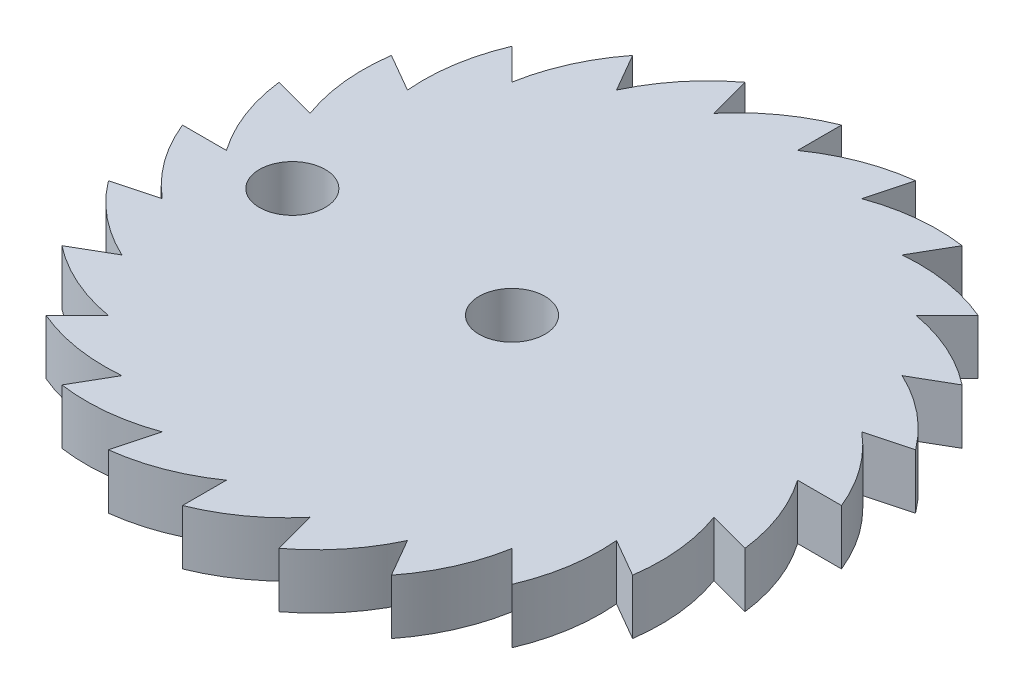
from build123d import *

# Parameters (mm, degrees)
SKETCH_1_R      = 1.5
EXTRUDE_1_DEPTH = 2.5


with BuildPart() as part:
    # 草图1 → 凸台-拉伸1 (new body)
    with BuildSketch(Plane(origin=(0, 0, 0), x_dir=(1, 0, 0), z_dir=(0, 1, 0))):
        with BuildLine():
            Line((3.882285677, 14.488887394), (3.364647586, 12.557035742))
            ThreePointArc((3.364647586, 12.557035742), (5.405611466, 13.028620317), (7.5, 12.990381057))
            Line((7.5, 12.990381057), (6.5, 11.258330249))
            ThreePointArc((6.5, 11.258330249), (8.593474792, 11.185605648), (10.606601718, 10.606601718))
            Line((10.606601718, 10.606601718), (9.192388155, 9.192388155))
            ThreePointArc((9.192388155, 9.192388155), (11.195707011, 8.580310438), (12.990381057, 7.5))
            Line((12.990381057, 7.5), (11.258330249, 6.5))
            ThreePointArc((11.258330249, 6.5), (13.0349703, 5.390281252), (14.488887394, 3.882285677))
            Line((14.488887394, 3.882285677), (12.557035742, 3.364647586))
            ThreePointArc((12.557035742, 3.364647586), (13.985921904, 1.832913306), (15, 0))
            Line((15, 0), (13, 0))
            ThreePointArc((13, 0), (13.983756043, -1.849364653), (14.488887394, -3.882285677))
            Line((14.488887394, -3.882285677), (12.557035742, -3.364647586))
            ThreePointArc((12.557035742, -3.364647586), (13.028620317, -5.405611466), (12.990381057, -7.5))
            Line((12.990381057, -7.5), (11.258330249, -6.5))
            ThreePointArc((11.258330249, -6.5), (11.185605648, -8.593474792), (10.606601718, -10.606601718))
            Line((10.606601718, -10.606601718), (9.192388155, -9.192388155))
            ThreePointArc((9.192388155, -9.192388155), (8.580310438, -11.195707011), (7.5, -12.990381057))
            Line((7.5, -12.990381057), (6.5, -11.258330249))
            ThreePointArc((6.5, -11.258330249), (5.390281252, -13.0349703), (3.882285677, -14.488887394))
            Line((3.882285677, -14.488887394), (3.364647586, -12.557035742))
            ThreePointArc((3.364647586, -12.557035742), (1.832913306, -13.985921904), (0, -15))
            Line((0, -15), (0, -13))
            ThreePointArc((0, -13), (-1.849364653, -13.983756043), (-3.882285677, -14.488887394))
            Line((-3.882285677, -14.488887394), (-3.364647586, -12.557035742))
            ThreePointArc((-3.364647586, -12.557035742), (-5.405611466, -13.028620317), (-7.5, -12.990381057))
            Line((-7.5, -12.990381057), (-6.5, -11.258330249))
            ThreePointArc((-6.5, -11.258330249), (-8.593474792, -11.185605648), (-10.606601718, -10.606601718))
            Line((-10.606601718, -10.606601718), (-9.192388155, -9.192388155))
            ThreePointArc((-9.192388155, -9.192388155), (-11.195707011, -8.580310438), (-12.990381057, -7.5))
            Line((-12.990381057, -7.5), (-11.258330249, -6.5))
            ThreePointArc((-11.258330249, -6.5), (-13.0349703, -5.390281252), (-14.488887394, -3.882285677))
            Line((-14.488887394, -3.882285677), (-12.557035742, -3.364647586))
            ThreePointArc((-12.557035742, -3.364647586), (-13.985921904, -1.832913306), (-15, 0))
            Line((-15, 0), (-13, 0))
            ThreePointArc((-13, 0), (-13.983756043, 1.849364653), (-14.488887394, 3.882285677))
            Line((-14.488887394, 3.882285677), (-12.557035742, 3.364647586))
            ThreePointArc((-12.557035742, 3.364647586), (-13.028620317, 5.405611466), (-12.990381057, 7.5))
            Line((-12.990381057, 7.5), (-11.258330249, 6.5))
            ThreePointArc((-11.258330249, 6.5), (-11.185605648, 8.593474792), (-10.606601718, 10.606601718))
            Line((-10.606601718, 10.606601718), (-9.192388155, 9.192388155))
            ThreePointArc((-9.192388155, 9.192388155), (-8.580310438, 11.195707011), (-7.5, 12.990381057))
            Line((-7.5, 12.990381057), (-6.5, 11.258330249))
            ThreePointArc((-6.5, 11.258330249), (-5.390281252, 13.0349703), (-3.882285677, 14.488887394))
            Line((-3.882285677, 14.488887394), (-3.364647586, 12.557035742))
            ThreePointArc((-3.364647586, 12.557035742), (-1.832913306, 13.985921904), (0, 15))
            Line((0, 15), (0, 13))
            ThreePointArc((0, 13), (1.849364653, 13.983756043), (3.882285677, 14.488887394))
        make_face()
        with Locations((-10, 0)):
            Circle(SKETCH_1_R, mode=Mode.SUBTRACT)
        Circle(SKETCH_1_R, mode=Mode.SUBTRACT)
    extrude(amount=EXTRUDE_1_DEPTH)


solid = part.part
